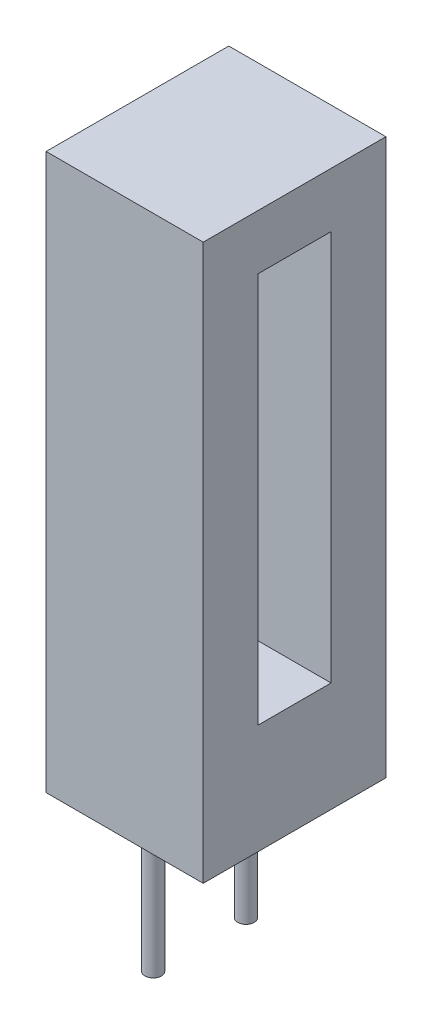
from build123d import *

# Parameters (mm, degrees)
SKETCH1_W           = 4.3
SKETCH1_H           = 15.2
BOSS_EXTRUDE1_DEPTH = 5
SKETCH2_W           = 2
SKETCH2_H           = 10.7
CUT_EXTRUDE1_DEPTH  = 2
SKETCH3_R           = 0.225
BOSS_EXTRUDE2_DEPTH = 4


with BuildPart() as part:
    # Sketch1 → Boss-Extrude1 (new body)
    with BuildSketch(Plane.XY):
        with Locations((2.15, 7.6)):
            Rectangle(SKETCH1_W, SKETCH1_H)
    extrude(amount=BOSS_EXTRUDE1_DEPTH)

    # Sketch2 → Cut-Extrude1 (cut)
    with BuildSketch(Plane(origin=(4.3, 0, 0), x_dir=(0, 0, -1), z_dir=(1, 0, 0))):
        with Locations((-2.5, 8.35)):
            Rectangle(SKETCH2_W, SKETCH2_H)
    extrude(amount=-CUT_EXTRUDE1_DEPTH, mode=Mode.SUBTRACT)

    # Sketch3 → Boss-Extrude2 (add)
    with BuildSketch(Plane.XZ):
        with Locations((1.7, 1.23)):
            Circle(SKETCH3_R)
        with Locations((1.7, 3.77)):
            Circle(SKETCH3_R)
    extrude(amount=BOSS_EXTRUDE2_DEPTH)


solid = part.part
